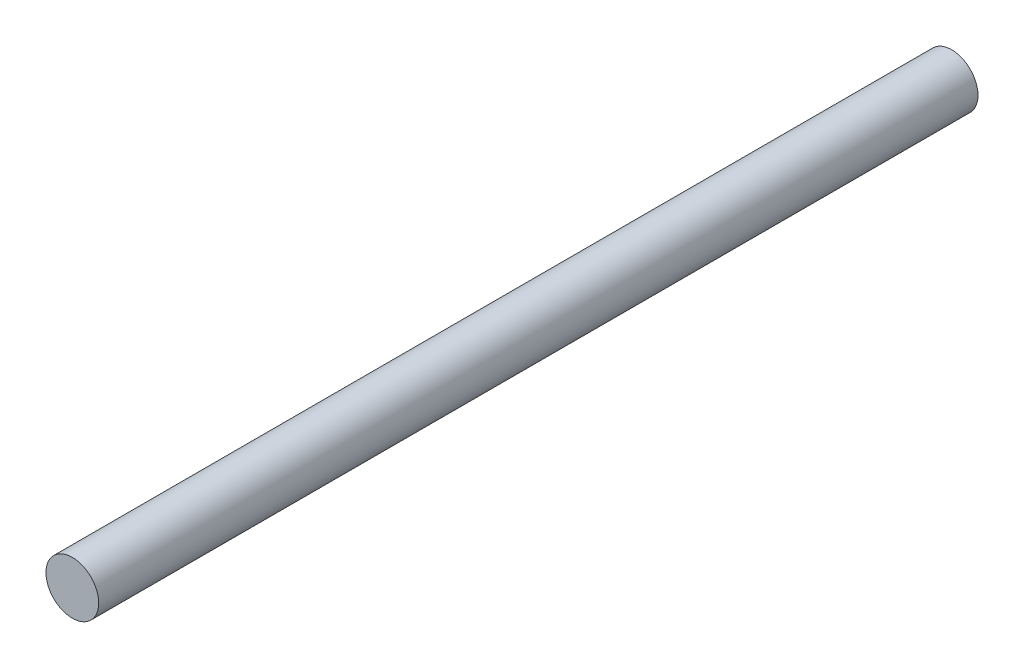
from build123d import *

# Parameters (mm, degrees)
BOSS_EXTRUDE1_DEPTH      = 50
BOSS_EXTRUDE1_DEPTH_BACK = 50
SKETCH1_R                = 3


with BuildPart() as part:
    # Sketch1 → Boss-Extrude1 (new, two sides: drawn at the far end of the back side and taken through both)
    with BuildSketch(Plane.XY.offset(-BOSS_EXTRUDE1_DEPTH_BACK)):
        Circle(SKETCH1_R)
    extrude(amount=BOSS_EXTRUDE1_DEPTH + BOSS_EXTRUDE1_DEPTH_BACK)


solid = part.part
